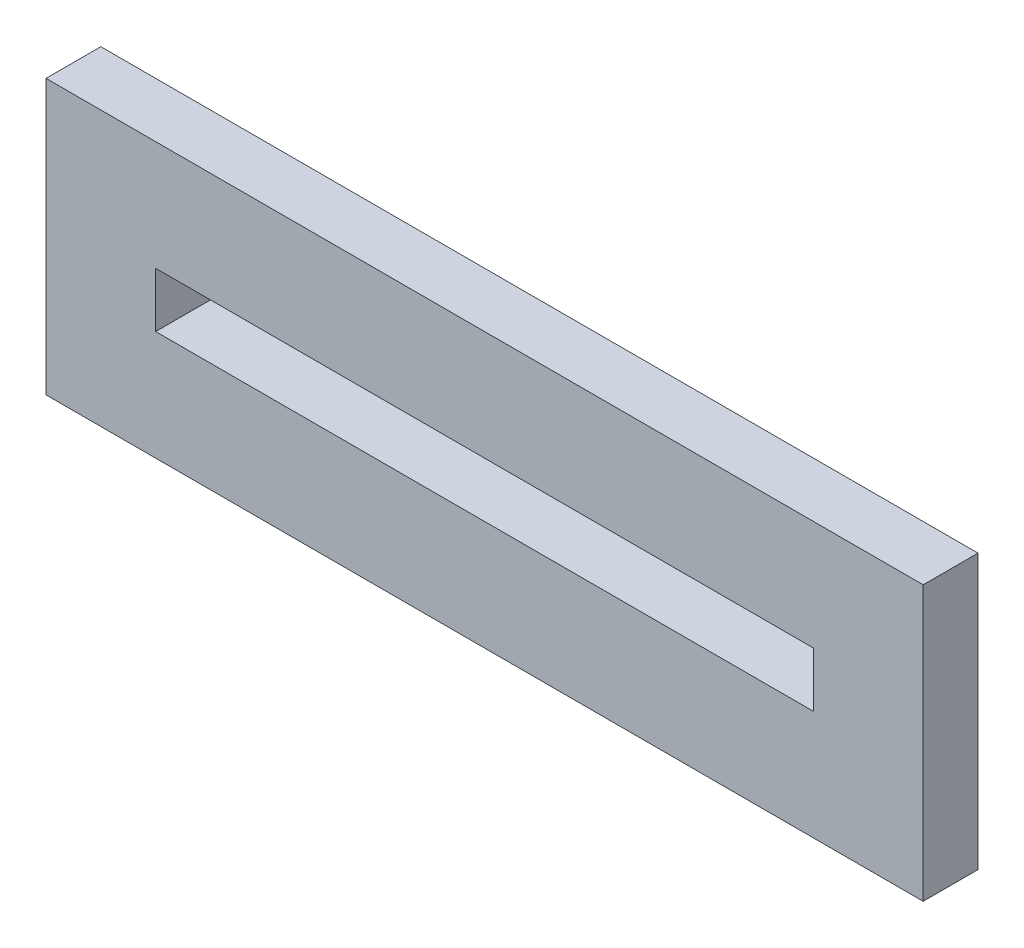
from build123d import *

# Parameters (mm, degrees)
SKETCH1_W           = 50.8
SKETCH1_H           = 15.875
SKETCH1_W_2         = 38.1
SKETCH1_H_2         = 3.175
BOSS_EXTRUDE1_DEPTH = 3.175


with BuildPart() as part:
    # Sketch1 → Boss-Extrude1 (new body)
    with BuildSketch(Plane.XY):
        with Locations((19.05, -1.5875)):
            Rectangle(SKETCH1_W, SKETCH1_H)
        with Locations((19.05, -1.5875)):
            Rectangle(SKETCH1_W_2, SKETCH1_H_2, mode=Mode.SUBTRACT)
    extrude(amount=BOSS_EXTRUDE1_DEPTH)


solid = part.part
